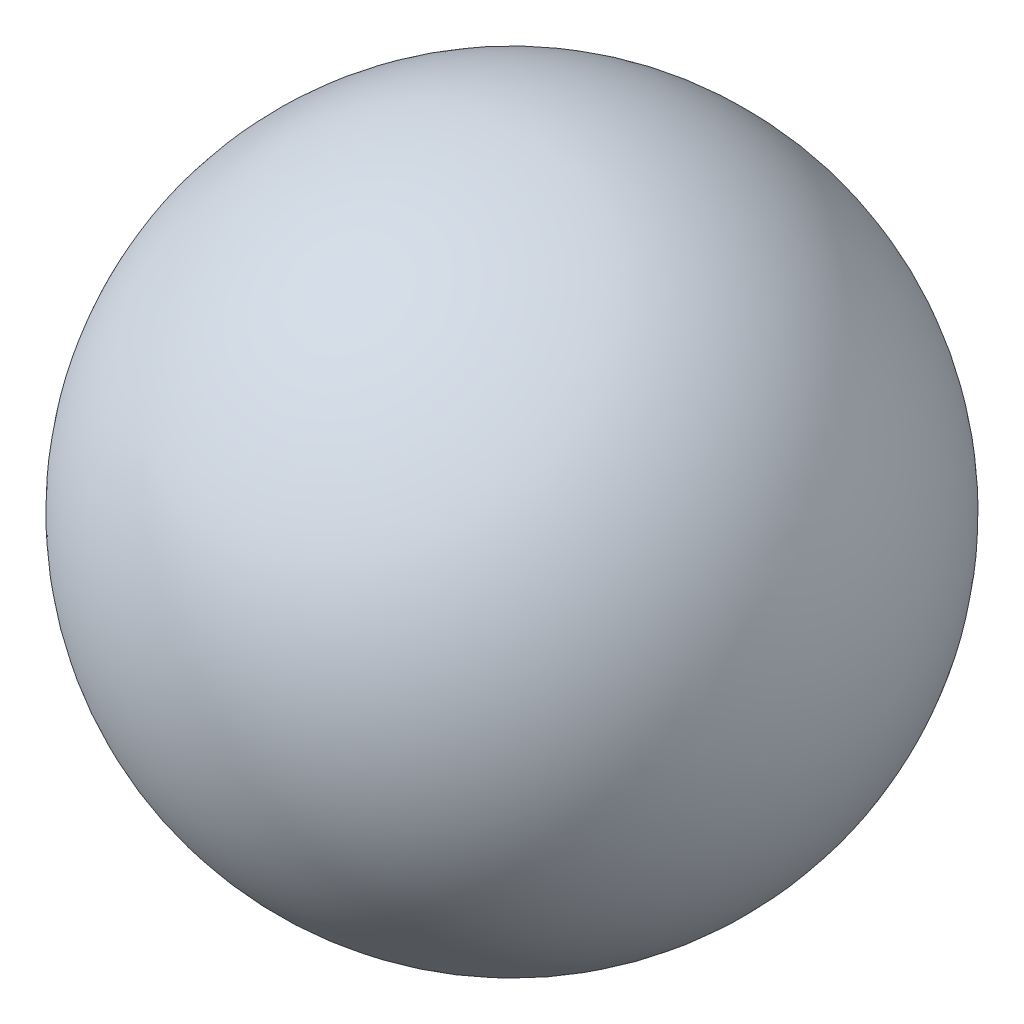
from build123d import *


with BuildPart() as part:
    # Sketch1 → Revolve2 (revolve)
    with BuildSketch(Plane.XY):
        with BuildLine():
            Line((1.651, 0), (-1.651, 0))
            ThreePointArc((-1.651, 0), (0, 1.651), (1.651, 0))
        make_face()
    revolve(axis=Axis((0, 0, 0), (1, 0, 0)))


solid = part.part
